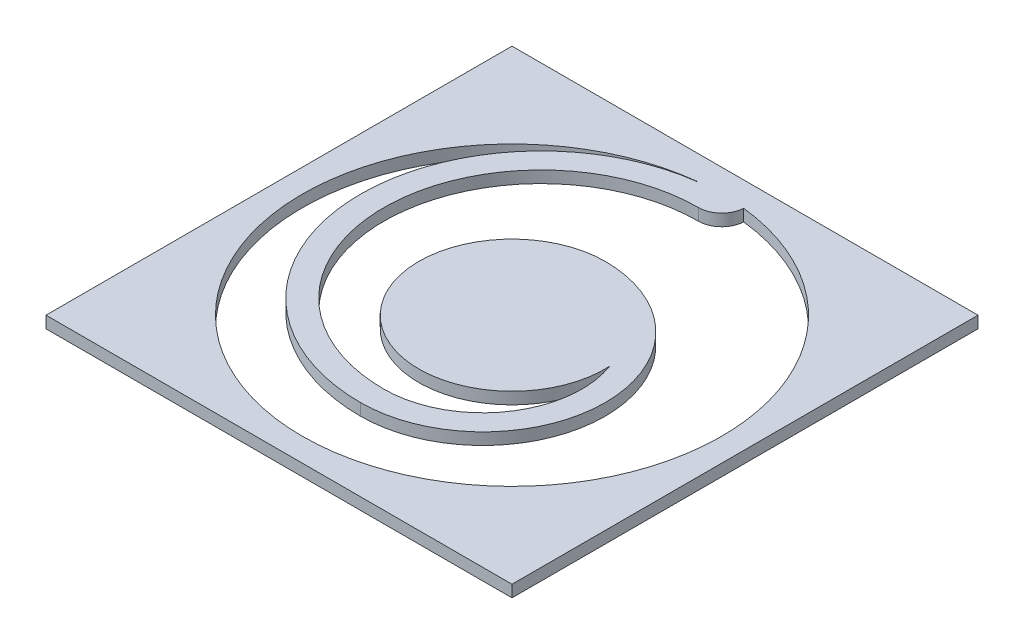
from build123d import *

# Parameters (mm, degrees)
SKETCH1_W           = 5
SKETCH1_H           = 5
BOSS_EXTRUDE1_DEPTH = 0.127


with BuildPart() as part:
    # Sketch1 → Boss-Extrude1 (new body)
    with BuildSketch(Plane(origin=(0, 0, 0), x_dir=(1, 0, 0), z_dir=(0, 1, 0))):
        with Locations((2.5, 2.5)):
            Rectangle(SKETCH1_W, SKETCH1_H)
        with BuildLine():
            ThreePointArc((2.749613899, 4.736111111), (2.5, 0.25), (2.250386101, 4.736111111))
            ThreePointArc((2.250386101, 4.736111111), (2.250450954, 4.734990888), (2.250520834, 4.733870968))
            ThreePointArc((2.250520834, 4.733870968), (0.566536463, 2.6875), (2.5, 0.875))
            ThreePointArc((2.5, 0.875), (3.8125, 2.1875), (2.5, 3.5))
            ThreePointArc((2.5, 3.5), (1.810797562, 1.775431163), (3.498749218, 2.55))
            ThreePointArc((3.498749218, 2.55), (3.370075428, 1.577684454), (2.5, 1.125))
            ThreePointArc((2.5, 1.125), (0.8125, 2.8125), (2.5, 4.5))
            ThreePointArc((2.5, 4.5), (2.671796068, 4.568379211), (2.749613899, 4.736111111))
        make_face(mode=Mode.SUBTRACT)
    extrude(amount=BOSS_EXTRUDE1_DEPTH)


solid = part.part
